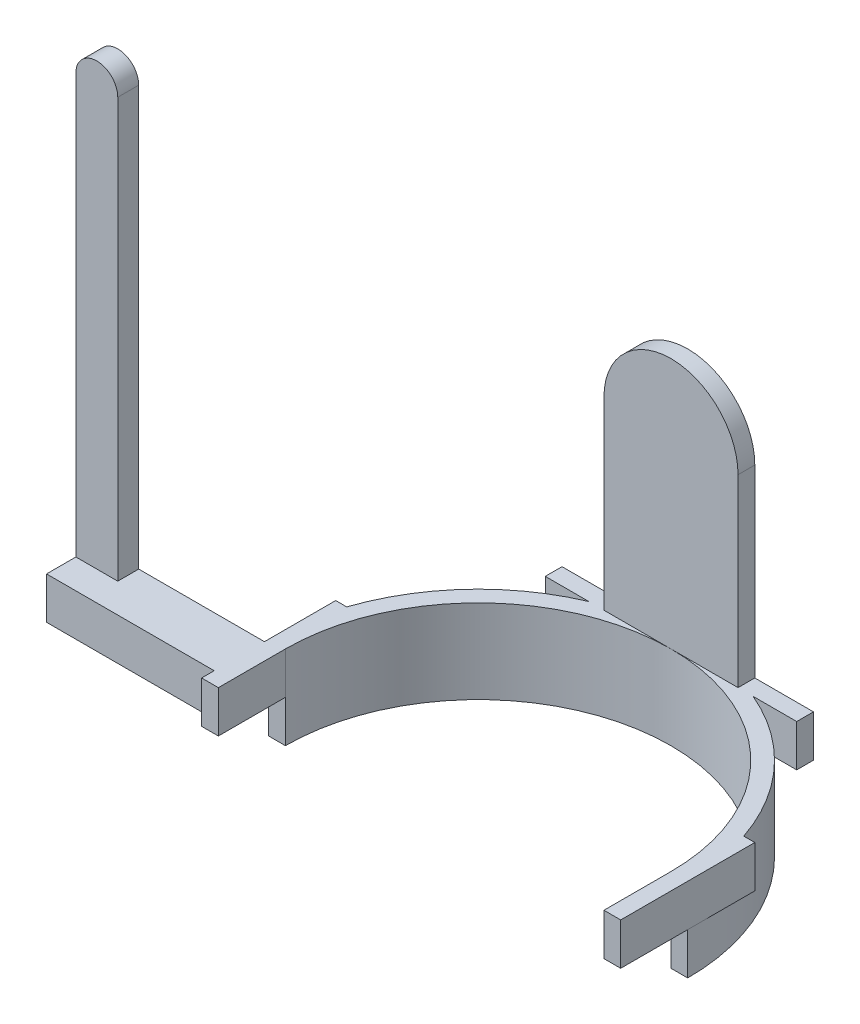
from build123d import *

# Parameters (mm, degrees)
EXTRUDE_1_DEPTH     = 10
EXTRUDE_2_DEPTH     = 10
SKETCH_4_W          = 32
SKETCH_4_H          = 4
EXTRUDE_3_DEPTH     = 60
CUT_EXTRUDE_1_DEPTH = 30
SKETCH_6_W          = 12
SKETCH_6_H          = 10
EXTRUDE_4_DEPTH     = 40
SKETCH_7_W          = 10
SKETCH_7_H          = 5
EXTRUDE_5_DEPTH     = 100
SKETCH_9_R          = 5
EXTRUDE_7_DEPTH     = 5


with BuildPart() as part:
    # 草图1 → 凸台-拉伸1 (new body)
    with BuildSketch(Plane(origin=(0, 0, 0), x_dir=(1, 0, 0), z_dir=(0, 1, 0))):
        with BuildLine():
            Line((-50, 0), (-46, 0))
            ThreePointArc((-46, 0), (0, 46), (46, 0))
            Line((46, 0), (50, 0))
            ThreePointArc((50, 0), (0, 50), (-50, 0))
        make_face()
    extrude(amount=EXTRUDE_1_DEPTH)

    # 草图3 → 凸台-拉伸2 (add)
    with BuildSketch(Plane(origin=(0, 10, 0), x_dir=(1, 0, 0), z_dir=(0, 1, 0))):
        with BuildLine():
            Line((-50, 16), (-47.370877129, 16))
            ThreePointArc((-47.370877129, 16), (-36.689752119, 33.968545589), (-19.595917942, 46))
            Line((-19.595917942, 46), (-30, 46))
            Line((-30, 46), (-30, 50))
            Line((-30, 50), (30, 50))
            Line((30, 50), (30, 46))
            Line((30, 46), (19.595917942, 46))
            ThreePointArc((19.595917942, 46), (36.689752119, 33.968545589), (47.370877129, 16))
            Line((47.370877129, 16), (50, 16))
            Line((50, 16), (50, -16))
            Line((50, -16), (46, -16))
            Line((46, -16), (46, 0))
            ThreePointArc((46, 0), (0, 46), (-46, 0))
            Line((-46, 0), (-46, -16))
            Line((-46, -16), (-50, -16))
            Line((-50, -16), (-50, 16))
        make_face()
    extrude(amount=EXTRUDE_2_DEPTH)

    # 草图4 → 凸台-拉伸3 (add)
    with BuildSketch(Plane(origin=(0, 20, 0), x_dir=(1, 0, 0), z_dir=(0, 1, 0))):
        with Locations((0, 48)):
            Rectangle(SKETCH_4_W, SKETCH_4_H)
    extrude(amount=EXTRUDE_3_DEPTH)

    # 草图5 → 切除-拉伸1 (cut)
    with BuildSketch(Plane(origin=(0, 0, -50), x_dir=(-1, 0, 0), z_dir=(0, 0, -1))):
        with BuildLine():
            Line((-16, 64), (-16, 97.905328476))
            Line((-16, 97.905328476), (16, 97.905328476))
            Line((16, 97.905328476), (16, 64))
            ThreePointArc((16, 64), (0, 80), (-16, 64))
        make_face()
    extrude(amount=-CUT_EXTRUDE_1_DEPTH, mode=Mode.SUBTRACT)

    # 草图6 → 凸台-拉伸4 (add)
    with BuildSketch(Plane.ZY.offset(50)):
        with Locations((7, 15)):
            Rectangle(SKETCH_6_W, SKETCH_6_H)
    extrude(amount=EXTRUDE_4_DEPTH)

    # 草图7 → 凸台-拉伸5 (add)
    with BuildSketch(Plane(origin=(0, 20, 0), x_dir=(1, 0, 0), z_dir=(0, 1, 0))):
        with Locations((-85, -3.5)):
            Rectangle(SKETCH_7_W, SKETCH_7_H)
    extrude(amount=EXTRUDE_5_DEPTH)

    # 草图9 → 凸台-拉伸7 (add)
    with BuildSketch(Plane.XY.offset(6)):
        with Locations((-85, 120)):
            Circle(SKETCH_9_R)
    extrude(amount=-EXTRUDE_7_DEPTH)


solid = part.part
